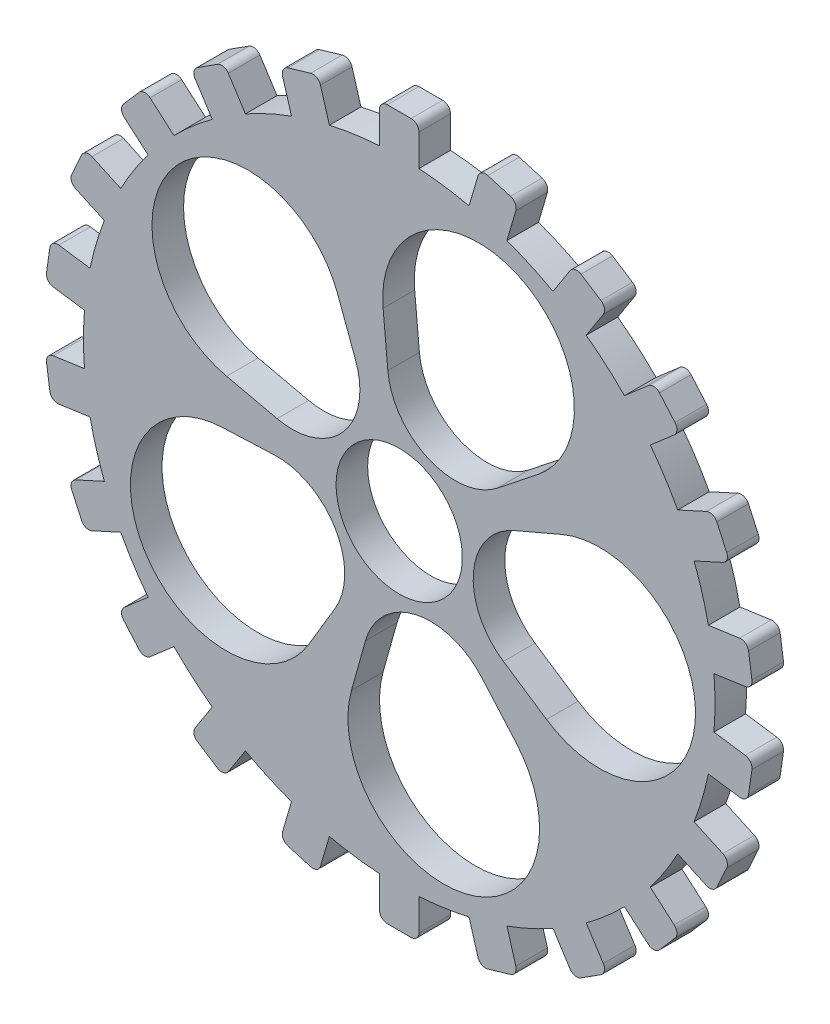
from build123d import *

# Parameters (mm, degrees)
BOSS_EXTRUDE1_DEPTH = 10.16
SKETCH5_R           = 20.32
CUT_EXTRUDE1_DEPTH  = 10.16
CUT_EXTRUDE2_DEPTH  = 10.16


with BuildPart() as part:
    # Sketch1 → Boss-Extrude1 (new body)
    with BuildSketch(Plane.XY):
        with BuildLine():
            Line((22.475286385, 99.082902167), (25.337689163, 108.831350779))
            ThreePointArc((25.337689163, 108.831350779), (26.55750889, 110.345054718), (28.49040201, 110.552862238))
            Line((28.49040201, 110.552862238), (35.801738469, 108.406060155))
            ThreePointArc((35.801738469, 108.406060155), (37.315442408, 107.186240428), (37.523249928, 105.253347307))
            Line((37.523249928, 105.253347307), (34.66084715, 95.504898695))
            ThreePointArc((34.66084715, 95.504898695), (42.206165321, 92.418610728), (49.479758734, 88.737328536))
            Line((49.479758734, 88.737328536), (54.972669439, 97.284464429))
            ThreePointArc((54.972669439, 97.284464429), (56.569537577, 98.393189792), (58.482681089, 98.048020726))
            Line((58.482681089, 98.048020726), (64.893033009, 93.928337697))
            ThreePointArc((64.893033009, 93.928337697), (66.001758372, 92.331469559), (65.656589306, 90.418326048))
            Line((65.656589306, 90.418326048), (60.163678601, 81.871190154))
            ThreePointArc((60.163678601, 81.871190154), (66.533850569, 76.784156754), (72.475675297, 71.202784287))
            Line((72.475675297, 71.202784287), (80.154090972, 77.856169344))
            ThreePointArc((80.154090972, 77.856169344), (81.998638762, 78.470093797), (83.737041155, 77.59991169))
            Line((83.737041155, 77.59991169), (88.727079948, 71.841099933))
            ThreePointArc((88.727079948, 71.841099933), (89.3410044, 69.996552144), (88.470822293, 68.25814975))
            Line((88.470822293, 68.25814975), (80.792406618, 61.604764693))
            ThreePointArc((80.792406618, 61.604764693), (85.471358936, 54.929107053), (89.600043677, 47.899813915))
            Line((89.600043677, 47.899813915), (98.84190475, 52.120430447))
            ThreePointArc((98.84190475, 52.120430447), (100.784697899, 52.189817481), (102.207524151, 50.865119312))
            Line((102.207524151, 50.865119312), (105.37298655, 43.933723508))
            ThreePointArc((105.37298655, 43.933723508), (105.442373583, 41.990930358), (104.117675415, 40.568104106))
            Line((104.117675415, 40.568104106), (94.875814342, 36.347487574))
            ThreePointArc((94.875814342, 36.347487574), (97.484486119, 28.624027775), (99.46554939, 20.716285491))
            Line((99.46554939, 20.716285491), (109.522135239, 22.162204248))
            ThreePointArc((109.522135239, 22.162204248), (111.405780202, 21.681432538), (112.397761391, 20.009537475))
            Line((112.397761391, 20.009537475), (113.482200459, 12.467098088))
            ThreePointArc((113.482200459, 12.467098088), (113.001428748, 10.583453125), (111.329533686, 9.591471936))
            Line((111.329533686, 9.591471936), (101.272947836, 8.145553179))
            ThreePointArc((101.272947836, 8.145553179), (101.6, 0), (101.272947836, -8.145553179))
            Line((101.272947836, -8.145553179), (111.329533686, -9.591471936))
            ThreePointArc((111.329533686, -9.591471936), (113.001428748, -10.583453125), (113.482200459, -12.467098088))
            Line((113.482200459, -12.467098088), (112.397761391, -20.009537475))
            ThreePointArc((112.397761391, -20.009537475), (111.405780202, -21.681432538), (109.522135239, -22.162204248))
            Line((109.522135239, -22.162204248), (99.46554939, -20.716285491))
            ThreePointArc((99.46554939, -20.716285491), (97.484486119, -28.624027775), (94.875814342, -36.347487574))
            Line((94.875814342, -36.347487574), (104.117675415, -40.568104106))
            ThreePointArc((104.117675415, -40.568104106), (105.442373583, -41.990930358), (105.37298655, -43.933723508))
            Line((105.37298655, -43.933723508), (102.207524151, -50.865119312))
            ThreePointArc((102.207524151, -50.865119312), (100.784697899, -52.189817481), (98.84190475, -52.120430447))
            Line((98.84190475, -52.120430447), (89.600043677, -47.899813915))
            ThreePointArc((89.600043677, -47.899813915), (85.471358936, -54.929107053), (80.792406618, -61.604764693))
            Line((80.792406618, -61.604764693), (88.470822293, -68.25814975))
            ThreePointArc((88.470822293, -68.25814975), (89.3410044, -69.996552144), (88.727079948, -71.841099933))
            Line((88.727079948, -71.841099933), (83.737041155, -77.59991169))
            ThreePointArc((83.737041155, -77.59991169), (81.998638762, -78.470093797), (80.154090972, -77.856169344))
            Line((80.154090972, -77.856169344), (72.475675297, -71.202784287))
            ThreePointArc((72.475675297, -71.202784287), (66.533850569, -76.784156754), (60.163678601, -81.871190154))
            Line((60.163678601, -81.871190154), (65.656589306, -90.418326048))
            ThreePointArc((65.656589306, -90.418326048), (66.001758372, -92.331469559), (64.893033009, -93.928337697))
            Line((64.893033009, -93.928337697), (58.482681089, -98.048020726))
            ThreePointArc((58.482681089, -98.048020726), (56.569537577, -98.393189792), (54.972669439, -97.284464429))
            Line((54.972669439, -97.284464429), (49.479758734, -88.737328536))
            ThreePointArc((49.479758734, -88.737328536), (42.206165321, -92.418610728), (34.66084715, -95.504898695))
            Line((34.66084715, -95.504898695), (37.523249928, -105.253347307))
            ThreePointArc((37.523249928, -105.253347307), (37.315442408, -107.186240428), (35.801738469, -108.406060155))
            Line((35.801738469, -108.406060155), (28.49040201, -110.552862238))
            ThreePointArc((28.49040201, -110.552862238), (26.55750889, -110.345054718), (25.337689163, -108.831350779))
            Line((25.337689163, -108.831350779), (22.475286385, -99.082902167))
            ThreePointArc((22.475286385, -99.082902167), (14.459187569, -100.565858495), (6.35, -101.401368334))
            Line((6.35, -101.401368334), (6.35, -111.561368334))
            ThreePointArc((6.35, -111.561368334), (5.606051224, -113.357419558), (3.81, -114.101368334))
            Line((3.81, -114.101368334), (-3.81, -114.101368334))
            ThreePointArc((-3.81, -114.101368334), (-5.606051224, -113.357419558), (-6.35, -111.561368334))
            Line((-6.35, -111.561368334), (-6.35, -101.401368334))
            ThreePointArc((-6.35, -101.401368334), (-14.459187569, -100.565858495), (-22.475286385, -99.082902167))
            Line((-22.475286385, -99.082902167), (-25.337689163, -108.831350779))
            ThreePointArc((-25.337689163, -108.831350779), (-26.55750889, -110.345054718), (-28.49040201, -110.552862238))
            Line((-28.49040201, -110.552862238), (-35.801738469, -108.406060155))
            ThreePointArc((-35.801738469, -108.406060155), (-37.315442408, -107.186240428), (-37.523249928, -105.253347307))
            Line((-37.523249928, -105.253347307), (-34.66084715, -95.504898695))
            ThreePointArc((-34.66084715, -95.504898695), (-42.206165321, -92.418610728), (-49.479758734, -88.737328536))
            Line((-49.479758734, -88.737328536), (-54.972669439, -97.284464429))
            ThreePointArc((-54.972669439, -97.284464429), (-56.569537577, -98.393189792), (-58.482681089, -98.048020726))
            Line((-58.482681089, -98.048020726), (-64.893033009, -93.928337697))
            ThreePointArc((-64.893033009, -93.928337697), (-66.001758372, -92.331469559), (-65.656589306, -90.418326048))
            Line((-65.656589306, -90.418326048), (-60.163678601, -81.871190154))
            ThreePointArc((-60.163678601, -81.871190154), (-66.533850569, -76.784156754), (-72.475675297, -71.202784287))
            Line((-72.475675297, -71.202784287), (-80.154090972, -77.856169344))
            ThreePointArc((-80.154090972, -77.856169344), (-81.998638762, -78.470093797), (-83.737041155, -77.59991169))
            Line((-83.737041155, -77.59991169), (-88.727079948, -71.841099933))
            ThreePointArc((-88.727079948, -71.841099933), (-89.3410044, -69.996552144), (-88.470822293, -68.25814975))
            Line((-88.470822293, -68.25814975), (-80.792406618, -61.604764693))
            ThreePointArc((-80.792406618, -61.604764693), (-85.471358936, -54.929107053), (-89.600043677, -47.899813915))
            Line((-89.600043677, -47.899813915), (-98.84190475, -52.120430447))
            ThreePointArc((-98.84190475, -52.120430447), (-100.784697899, -52.189817481), (-102.207524151, -50.865119312))
            Line((-102.207524151, -50.865119312), (-105.37298655, -43.933723508))
            ThreePointArc((-105.37298655, -43.933723508), (-105.442373583, -41.990930358), (-104.117675415, -40.568104106))
            Line((-104.117675415, -40.568104106), (-94.875814342, -36.347487574))
            ThreePointArc((-94.875814342, -36.347487574), (-97.484486119, -28.624027775), (-99.46554939, -20.716285491))
            Line((-99.46554939, -20.716285491), (-109.522135239, -22.162204248))
            ThreePointArc((-109.522135239, -22.162204248), (-111.405780202, -21.681432538), (-112.397761391, -20.009537475))
            Line((-112.397761391, -20.009537475), (-113.482200459, -12.467098088))
            ThreePointArc((-113.482200459, -12.467098088), (-113.001428748, -10.583453125), (-111.329533686, -9.591471936))
            Line((-111.329533686, -9.591471936), (-101.272947836, -8.145553179))
            ThreePointArc((-101.272947836, -8.145553179), (-101.6, 0), (-101.272947836, 8.145553179))
            Line((-101.272947836, 8.145553179), (-111.329533686, 9.591471936))
            ThreePointArc((-111.329533686, 9.591471936), (-113.001428748, 10.583453125), (-113.482200459, 12.467098088))
            Line((-113.482200459, 12.467098088), (-112.397761391, 20.009537475))
            ThreePointArc((-112.397761391, 20.009537475), (-111.405780202, 21.681432538), (-109.522135239, 22.162204248))
            Line((-109.522135239, 22.162204248), (-99.46554939, 20.716285491))
            ThreePointArc((-99.46554939, 20.716285491), (-97.484486119, 28.624027775), (-94.875814342, 36.347487574))
            Line((-94.875814342, 36.347487574), (-104.117675415, 40.568104106))
            ThreePointArc((-104.117675415, 40.568104106), (-105.442373583, 41.990930358), (-105.37298655, 43.933723508))
            Line((-105.37298655, 43.933723508), (-102.207524151, 50.865119312))
            ThreePointArc((-102.207524151, 50.865119312), (-100.784697899, 52.189817481), (-98.84190475, 52.120430447))
            Line((-98.84190475, 52.120430447), (-89.600043677, 47.899813915))
            ThreePointArc((-89.600043677, 47.899813915), (-85.471358936, 54.929107053), (-80.792406618, 61.604764693))
            Line((-80.792406618, 61.604764693), (-88.470822293, 68.25814975))
            ThreePointArc((-88.470822293, 68.25814975), (-89.3410044, 69.996552144), (-88.727079948, 71.841099933))
            Line((-88.727079948, 71.841099933), (-83.737041155, 77.59991169))
            ThreePointArc((-83.737041155, 77.59991169), (-81.998638762, 78.470093797), (-80.154090972, 77.856169344))
            Line((-80.154090972, 77.856169344), (-72.475675297, 71.202784287))
            ThreePointArc((-72.475675297, 71.202784287), (-66.533850569, 76.784156754), (-60.163678601, 81.871190154))
            Line((-60.163678601, 81.871190154), (-65.656589306, 90.418326048))
            ThreePointArc((-65.656589306, 90.418326048), (-66.001758372, 92.331469559), (-64.893033009, 93.928337697))
            Line((-64.893033009, 93.928337697), (-58.482681089, 98.048020726))
            ThreePointArc((-58.482681089, 98.048020726), (-56.569537577, 98.393189792), (-54.972669439, 97.284464429))
            Line((-54.972669439, 97.284464429), (-49.479758734, 88.737328536))
            ThreePointArc((-49.479758734, 88.737328536), (-42.206165321, 92.418610728), (-34.66084715, 95.504898695))
            Line((-34.66084715, 95.504898695), (-37.523249928, 105.253347307))
            ThreePointArc((-37.523249928, 105.253347307), (-37.315442408, 107.186240428), (-35.801738469, 108.406060155))
            Line((-35.801738469, 108.406060155), (-28.49040201, 110.552862238))
            ThreePointArc((-28.49040201, 110.552862238), (-26.55750889, 110.345054718), (-25.337689163, 108.831350779))
            Line((-25.337689163, 108.831350779), (-22.475286385, 99.082902167))
            ThreePointArc((-22.475286385, 99.082902167), (-14.459187569, 100.565858495), (-6.35, 101.401368334))
            Line((-6.35, 101.401368334), (-6.35, 111.561368334))
            ThreePointArc((-6.35, 111.561368334), (-5.606051224, 113.357419558), (-3.81, 114.101368334))
            Line((-3.81, 114.101368334), (3.81, 114.101368334))
            ThreePointArc((3.81, 114.101368334), (5.606051224, 113.357419558), (6.35, 111.561368334))
            Line((6.35, 111.561368334), (6.35, 101.401368334))
            ThreePointArc((6.35, 101.401368334), (14.459187569, 100.565858495), (22.475286385, 99.082902167))
        make_face()
    extrude(amount=BOSS_EXTRUDE1_DEPTH)

    # Sketch5 → Cut-Extrude1 (cut)
    with BuildSketch(Plane(origin=(0, 0, 0), x_dir=(-1, 0, 0), z_dir=(0, 0, -1))):
        Circle(SKETCH5_R)
    extrude(amount=-CUT_EXTRUDE1_DEPTH, mode=Mode.SUBTRACT)

    # Sketch7 → Cut-Extrude2 (cut)
    with BuildSketch(Plane(origin=(0, 0, 0), x_dir=(-1, 0, 0), z_dir=(0, 0, -1))):
        with BuildLine():
            Line((56.901177996, -2.335804465), (40.242922299, -1.651979817))
            ThreePointArc((40.242922299, -1.651979817), (20.612516834, -12.280303087), (20.611568221, -34.603252564))
            Line((20.611568221, -34.603252564), (29.143572213, -48.927009294))
            ThreePointArc((29.143572213, -48.927009294), (82.12787633, -48.929260863), (56.901177996, -2.335804465))
        make_face()
        with BuildLine():
            Line((19.804913058, 53.394432842), (14.006873064, 37.76280365))
            ThreePointArc((14.006873064, 37.76280365), (18.048880272, 15.808846103), (39.278973697, 8.909773164))
            Line((39.278973697, 8.909773164), (55.538210102, 12.597906905))
            ThreePointArc((55.538210102, 12.597906905), (71.913401879, 62.988278825), (19.804913058, 53.394432842))
        make_face()
        with BuildLine():
            Line((15.361948943, -54.838039393), (10.864620724, -38.783783325))
            ThreePointArc((10.864620724, -38.783783325), (-5.309644274, -23.398490803), (-26.540323975, -30.29575937))
            Line((-26.540323975, -30.29575937), (-37.526491922, -42.836461617))
            ThreePointArc((-37.526491922, -42.836461617), (-21.155582883, -93.228225082), (15.361948943, -54.838039393))
        make_face()
        with BuildLine():
            Line((-47.406971415, -31.555967756), (-33.528217417, -22.31771649))
            ThreePointArc((-33.528217417, -22.31771649), (-23.894057464, -2.180759514), (-37.01439051, 15.879443558))
            Line((-37.01439051, 15.879443558), (-52.336219699, 22.452620057))
            ThreePointArc((-52.336219699, 22.452620057), (-95.202745604, -8.688950949), (-47.406971415, -31.555967756))
        make_face()
        with BuildLine():
            Line((-44.661068581, 35.335378772), (-31.58619867, 24.990675983))
            ThreePointArc((-31.58619867, 24.990675983), (-9.457695368, 22.050707301), (3.664172567, 40.109795212))
            Line((3.664172567, 40.109795212), (5.180929305, 56.712943949))
            ThreePointArc((5.180929305, 56.712943949), (-37.682949723, 87.858158069), (-44.661068581, 35.335378772))
        make_face()
    extrude(amount=-CUT_EXTRUDE2_DEPTH, mode=Mode.SUBTRACT)


solid = part.part
